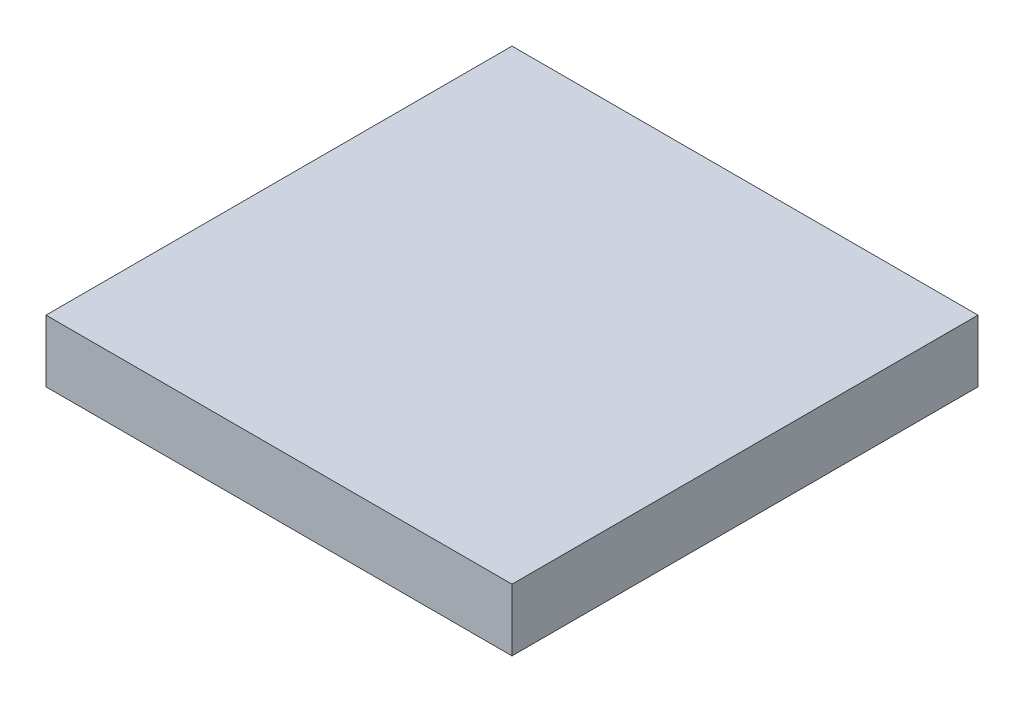
from build123d import *

# Parameters (mm, degrees)
SKETCH1_W           = 300
SKETCH1_H           = 300
BOSS_EXTRUDE1_DEPTH = 40


with BuildPart() as part:
    # Sketch1 → Boss-Extrude1 (new body)
    with BuildSketch(Plane(origin=(0, 0, 0), x_dir=(1, 0, 0), z_dir=(0, 1, 0))):
        with Locations((21.034482759, -67.24137931)):
            Rectangle(SKETCH1_W, SKETCH1_H)
    extrude(amount=BOSS_EXTRUDE1_DEPTH)


solid = part.part
